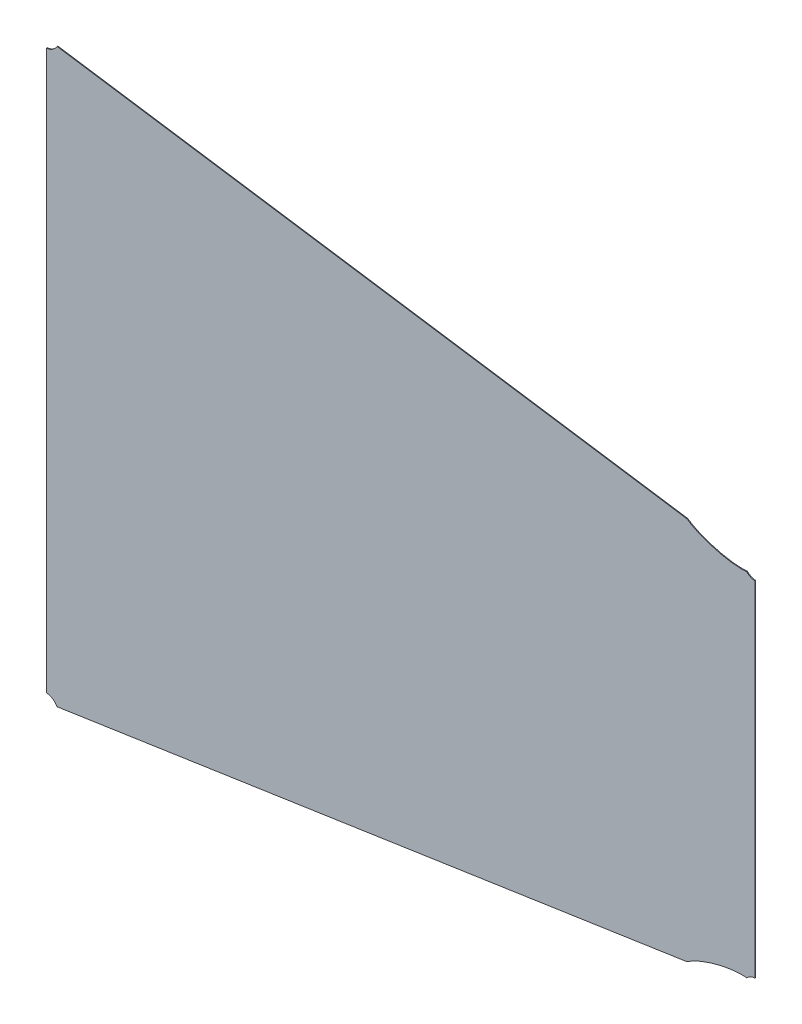
from build123d import *

# Parameters (mm, degrees)
DODANIE_WYCI_GNI_CIE1_DEPTH = 0.75


with BuildPart() as part:
    # Szkic2 → Dodanie-wyciągnięcie1 (new body)
    with BuildSketch(Plane.XY):
        with BuildLine():
            Line((-198.180056235, -174.343371382), (-198.180056235, 174.343371382))
            add(Edge.make_bspline(
                [(-198.180056235, 174.343371382), (-198.814001088, 174.406171049), (-200.029378534, 174.610462196), (-202.057107029, 175.259966245), (-203.861424394, 176.203690636), (-205.297190597, 177.249011775), (-206.016868944, 177.898350742), (-206.350638573, 178.234256298)],
                knots=[0.983916118, 0.983916118, 0.983916118, 0.983916118, 1.01810112, 1.052286122, 1.086471125, 1.103563626, 1.120656127, 1.120656127, 1.120656127, 1.120656127], degree=3))
            add(Edge.make_bspline(
                [(-206.350638573, 178.234256298), (-206.752993703, 178.198264306), (-207.539928278, 178.138556667), (-209.26679718, 178.051541981), (-211.615353293, 178.018552884), (-214.778879334, 178.117030022), (-219.442272991, 178.45896865), (-226.083190988, 179.327493296), (-235.041515621, 181.174554614), (-244.401007092, 183.815912629), (-251.88971958, 186.553469872), (-257.317102506, 188.930286392), (-261.034871731, 190.768565716), (-263.783209225, 192.309993434), (-265.771886977, 193.543556647), (-266.665075006, 194.137485785), (-267.11637499, 194.44902024)],
                knots=[0.004638779, 0.004638779, 0.004638779, 0.004638779, 0.015597592, 0.026556404, 0.04847403, 0.070391656, 0.092309282, 0.136144533, 0.179979785, 0.223815036, 0.267650288, 0.289567914, 0.311485539, 0.333403165, 0.344361978, 0.355320791, 0.355320791, 0.355320791, 0.355320791], degree=3))
            Line((-267.11637499, 194.44902024), (-905.657427312, 289.90714954))
            add(Edge.make_bspline(
                [(-905.657427312, 289.90714954), (-906.006104535, 289.315247268), (-906.804551959, 288.159312543), (-908.572469256, 286.249166576), (-911.015586006, 284.522093086), (-913.404414633, 283.603556478), (-915.194323394, 283.225046758), (-916.005259178, 283.136981023), (-916.423901621, 283.11129086)],
                knots=[0.312267878, 0.312267878, 0.312267878, 0.312267878, 0.332062336, 0.351856793, 0.391445708, 0.431034623, 0.450829081, 0.470623538, 0.470623538, 0.470623538, 0.470623538], degree=3))
            Line((-916.423901621, 283.11129086), (-916.423901621, -283.11129086))
            add(Edge.make_bspline(
                [(-916.423901621, -283.11129086), (-916.005259178, -283.136981023), (-915.194323394, -283.225046758), (-913.404414633, -283.603556478), (-911.015586006, -284.522093086), (-908.572469256, -286.249166576), (-906.804551959, -288.159312543), (-906.006104535, -289.315247268), (-905.657427312, -289.90714954)],
                knots=[0.029376462, 0.029376462, 0.029376462, 0.029376462, 0.049170919, 0.068965377, 0.108554292, 0.148143207, 0.167937664, 0.187732122, 0.187732122, 0.187732122, 0.187732122], degree=3))
            Line((-905.657427312, -289.90714954), (-267.11637499, -194.44902024))
            add(Edge.make_bspline(
                [(-267.11637499, -194.44902024), (-266.665075006, -194.137485784), (-265.771886977, -193.543556647), (-263.783209225, -192.309993434), (-261.034871731, -190.768565716), (-257.317102506, -188.930286392), (-251.88971958, -186.553469872), (-244.401007092, -183.815912629), (-235.041515621, -181.174554614), (-226.083190988, -179.327493296), (-219.442272991, -178.45896865), (-214.778879334, -178.117030022), (-211.615353293, -178.018552884), (-209.26679718, -178.051541981), (-207.539928278, -178.138556667), (-206.752993703, -178.198264306), (-206.350638573, -178.234256298)],
                knots=[0.644679209, 0.644679209, 0.644679209, 0.644679209, 0.655638022, 0.666596835, 0.688514461, 0.710432086, 0.732349712, 0.776184964, 0.820020215, 0.863855467, 0.907690718, 0.929608344, 0.95152597, 0.973443596, 0.984402408, 0.995361221, 0.995361221, 0.995361221, 0.995361221], degree=3))
            add(Edge.make_bspline(
                [(-206.350638573, -178.234256298), (-206.016868944, -177.898350742), (-205.297190597, -177.249011775), (-203.861424394, -176.203690636), (-202.057107029, -175.259966245), (-200.029378534, -174.610462196), (-198.814001088, -174.406171049), (-198.180056235, -174.343371382)],
                knots=[0.379343873, 0.379343873, 0.379343873, 0.379343873, 0.396436374, 0.413528875, 0.447713878, 0.48189888, 0.516083882, 0.516083882, 0.516083882, 0.516083882], degree=3))
        make_face()
    extrude(amount=DODANIE_WYCI_GNI_CIE1_DEPTH)


solid = part.part
